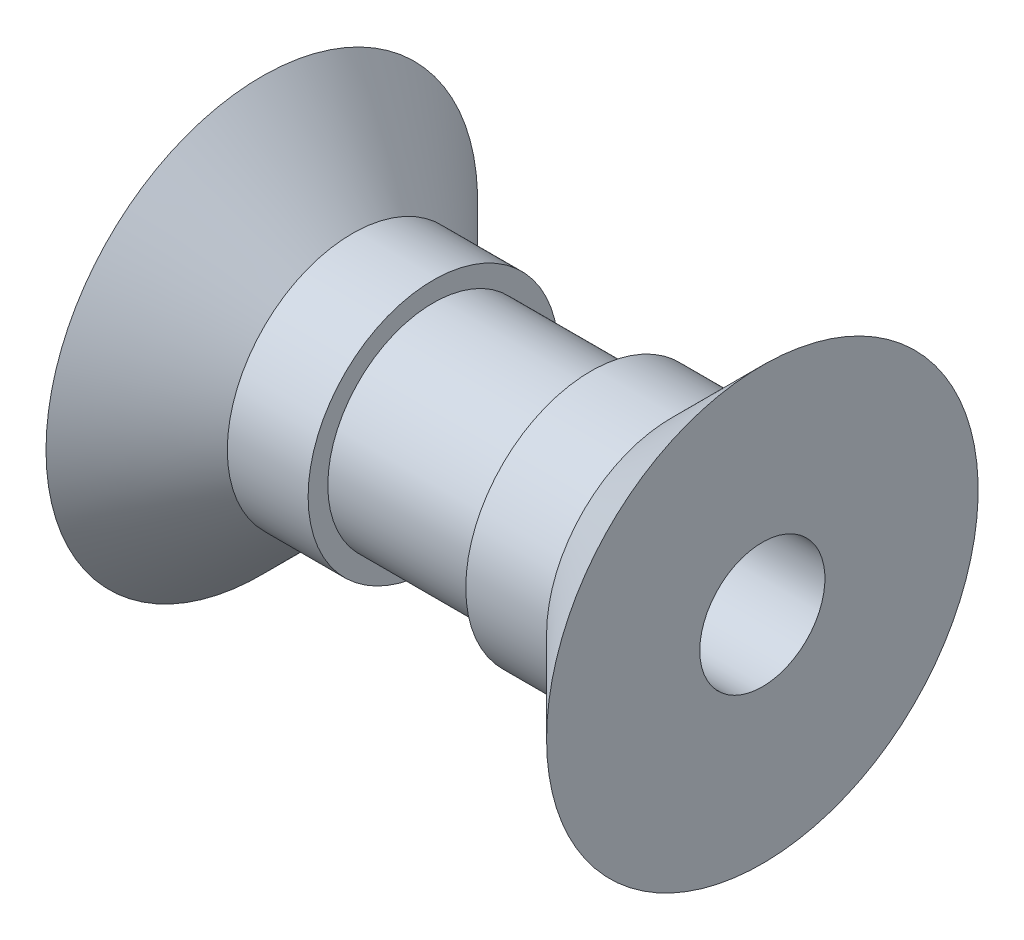
from build123d import *

# Parameters (mm, degrees)
SKETCH2_R          = 1.5875
CUT_EXTRUDE1_DEPTH = 13.7


with BuildPart() as part:
    # Sketch1 → Revolve1 (revolve)
    with BuildSketch(Plane.XY):
        Polygon((-6.35, 0), (-6.35, 5.475), (-4.05, 3.175), (-2, 3.175), (-2, 2.675), (2, 2.675), (2, 3.175), (4.05, 3.175), (6.35, 5.475), (6.35, 0), align=None)
    revolve(axis=Axis((-93.951812963, 0, 0), (1, 0, 0)))

    # Sketch2 → Cut-Extrude1 (cut, through all)
    with BuildSketch(Plane.ZY.offset(6.35)):
        Circle(SKETCH2_R)
    extrude(amount=-CUT_EXTRUDE1_DEPTH, mode=Mode.SUBTRACT)


solid = part.part
